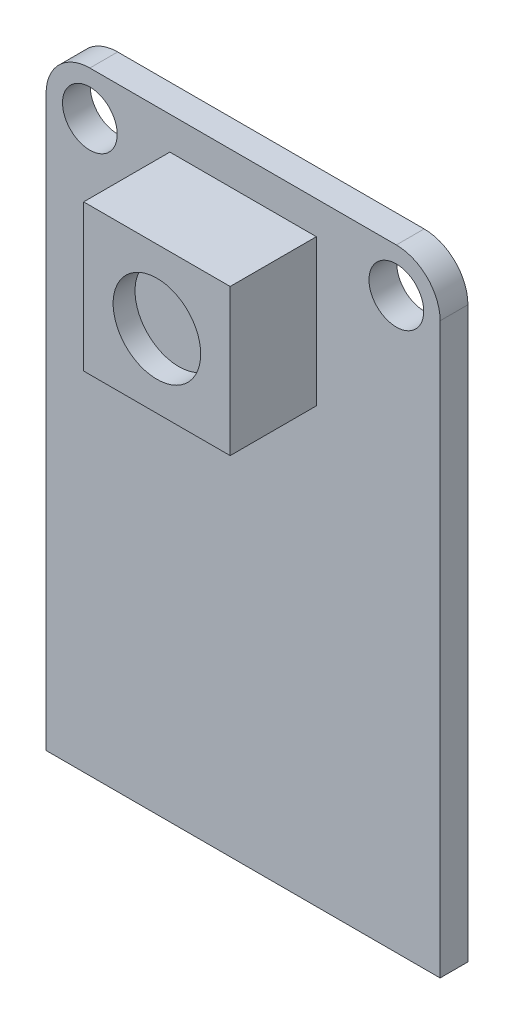
from build123d import *

# Parameters (mm, degrees)
SKETCH1_W           = 22.86
SKETCH1_H           = 35.56
BOSS_EXTRUDE1_DEPTH = 1.6129
FILLET1_R           = 2.54
SKETCH2_W           = 8.5
SKETCH2_H           = 8.5
BOSS_EXTRUDE2_DEPTH = 5
CUT_EXTRUDE1_REACH  = 3.613
SKETCH3_R           = 1.5875
SKETCH4_R           = 2.54
CUT_EXTRUDE2_DEPTH  = 1.27


with BuildPart() as part:
    # Sketch1 → Boss-Extrude1 (new body)
    with BuildSketch(Plane.XY):
        Rectangle(SKETCH1_W, SKETCH1_H)
    extrude(amount=BOSS_EXTRUDE1_DEPTH)

    # Fillet1
    fillet1_edges = [part.edges().sort_by_distance(p)[0] for p in [
        (-11.43, 17.78, 0.80645),
        (11.43, 17.78, 0.80645),
    ]]
    fillet(fillet1_edges, radius=FILLET1_R)

    # Sketch2 → Boss-Extrude2 (add)
    with BuildSketch(Plane.XY.offset(1.6129)):
        with Locations((0, 11.625)):
            Rectangle(SKETCH2_W, SKETCH2_H)
    extrude(amount=BOSS_EXTRUDE2_DEPTH)

    # Sketch3 → Cut-Extrude1 (cut, up to next)
    with BuildSketch(Plane.XY.offset(1.6129), mode=Mode.PRIVATE) as cut_extrude1_sk1:
        with Locations((-8.89, 15.24)):
            Circle(SKETCH3_R)
    cut_extrude1_tool1 = extrude(cut_extrude1_sk1.sketch, amount=-CUT_EXTRUDE1_REACH, mode=Mode.PRIVATE) & part.part
    add(cut_extrude1_tool1.solids().sort_by_distance((-8.89, 15.24, 1.6129))[0], mode=Mode.SUBTRACT)
    # Sketch3 → Cut-Extrude1 (cut, up to next)
    with BuildSketch(Plane.XY.offset(1.6129), mode=Mode.PRIVATE) as cut_extrude1_sk2:
        with Locations((8.89, 15.24)):
            Circle(SKETCH3_R)
    cut_extrude1_tool2 = extrude(cut_extrude1_sk2.sketch, amount=-CUT_EXTRUDE1_REACH, mode=Mode.PRIVATE) & part.part
    add(cut_extrude1_tool2.solids().sort_by_distance((8.89, 15.24, 1.6129))[0], mode=Mode.SUBTRACT)

    # Sketch4 → Cut-Extrude2 (cut)
    with BuildSketch(Plane.XY.offset(6.6129)):
        with Locations((0, 11.625)):
            Circle(SKETCH4_R)
    extrude(amount=-CUT_EXTRUDE2_DEPTH, mode=Mode.SUBTRACT)


solid = part.part
